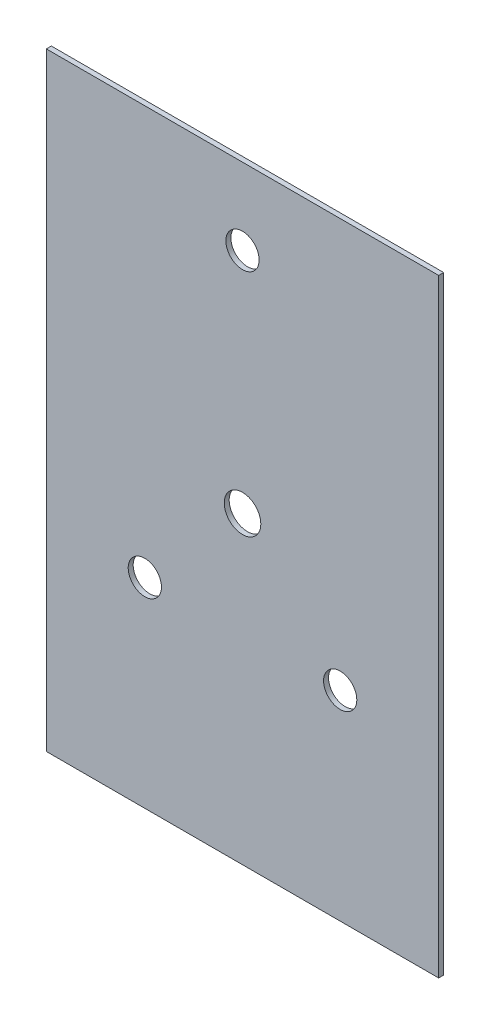
from build123d import *

# Parameters (mm, degrees)
SKETCH1_W           = 236
SKETCH1_H           = 366
BOSS_EXTRUDE1_DEPTH = 3
CUT_EXTRUDE2_REACH  = 5
SKETCH2_R           = 7.5
CUT_EXTRUDE3_REACH  = 5
SKETCH3_R           = 11
SKETCH3_R_2         = 10


with BuildPart() as part:
    # Sketch1 → Boss-Extrude1 (new body)
    with BuildSketch(Plane.XY):
        Rectangle(SKETCH1_W, SKETCH1_H)
    extrude(amount=BOSS_EXTRUDE1_DEPTH)

    # Sketch2 → Cut-Extrude2 (cut, up to next)
    with BuildSketch(Plane(origin=(0, 0, 0), x_dir=(-1, 0, 0), z_dir=(0, 0, -1)), mode=Mode.PRIVATE) as cut_extrude2_sk1:
        with Locations((0, 137.5)):
            Circle(SKETCH2_R)
    cut_extrude2_tool1 = extrude(cut_extrude2_sk1.sketch, amount=-CUT_EXTRUDE2_REACH, mode=Mode.PRIVATE) & part.part
    add(cut_extrude2_tool1.solids().sort_by_distance((0, 137.5, 0))[0], mode=Mode.SUBTRACT)

    # Sketch3 → Cut-Extrude3 (cut, up to next)
    with BuildSketch(Plane.XY.offset(3), mode=Mode.PRIVATE) as cut_extrude3_sk1:
        Circle(SKETCH3_R)
    cut_extrude3_tool1 = extrude(cut_extrude3_sk1.sketch, amount=-CUT_EXTRUDE3_REACH, mode=Mode.PRIVATE) & part.part
    add(cut_extrude3_tool1.solids().sort_by_distance((0, 0, 3))[0], mode=Mode.SUBTRACT)
    # Sketch3 → Cut-Extrude3 (cut, up to next)
    with BuildSketch(Plane.XY.offset(3), mode=Mode.PRIVATE) as cut_extrude3_sk2:
        with Locations((-58.75, -62.75)):
            Circle(SKETCH3_R_2)
    cut_extrude3_tool2 = extrude(cut_extrude3_sk2.sketch, amount=-CUT_EXTRUDE3_REACH, mode=Mode.PRIVATE) & part.part
    add(cut_extrude3_tool2.solids().sort_by_distance((-58.75, -62.75, 3))[0], mode=Mode.SUBTRACT)
    # Sketch3 → Cut-Extrude3 (cut, up to next)
    with BuildSketch(Plane.XY.offset(3), mode=Mode.PRIVATE) as cut_extrude3_sk3:
        with Locations((58.75, -62.75)):
            Circle(SKETCH3_R_2)
    cut_extrude3_tool3 = extrude(cut_extrude3_sk3.sketch, amount=-CUT_EXTRUDE3_REACH, mode=Mode.PRIVATE) & part.part
    add(cut_extrude3_tool3.solids().sort_by_distance((58.75, -62.75, 3))[0], mode=Mode.SUBTRACT)
    # Sketch3 → Cut-Extrude3 (cut, up to next)
    with BuildSketch(Plane.XY.offset(3), mode=Mode.PRIVATE) as cut_extrude3_sk4:
        with Locations((0, 137.015625)):
            Circle(SKETCH3_R_2)
    cut_extrude3_tool4 = extrude(cut_extrude3_sk4.sketch, amount=-CUT_EXTRUDE3_REACH, mode=Mode.PRIVATE) & part.part
    add(cut_extrude3_tool4.solids().sort_by_distance((0, 137.015625, 3))[0], mode=Mode.SUBTRACT)


solid = part.part
